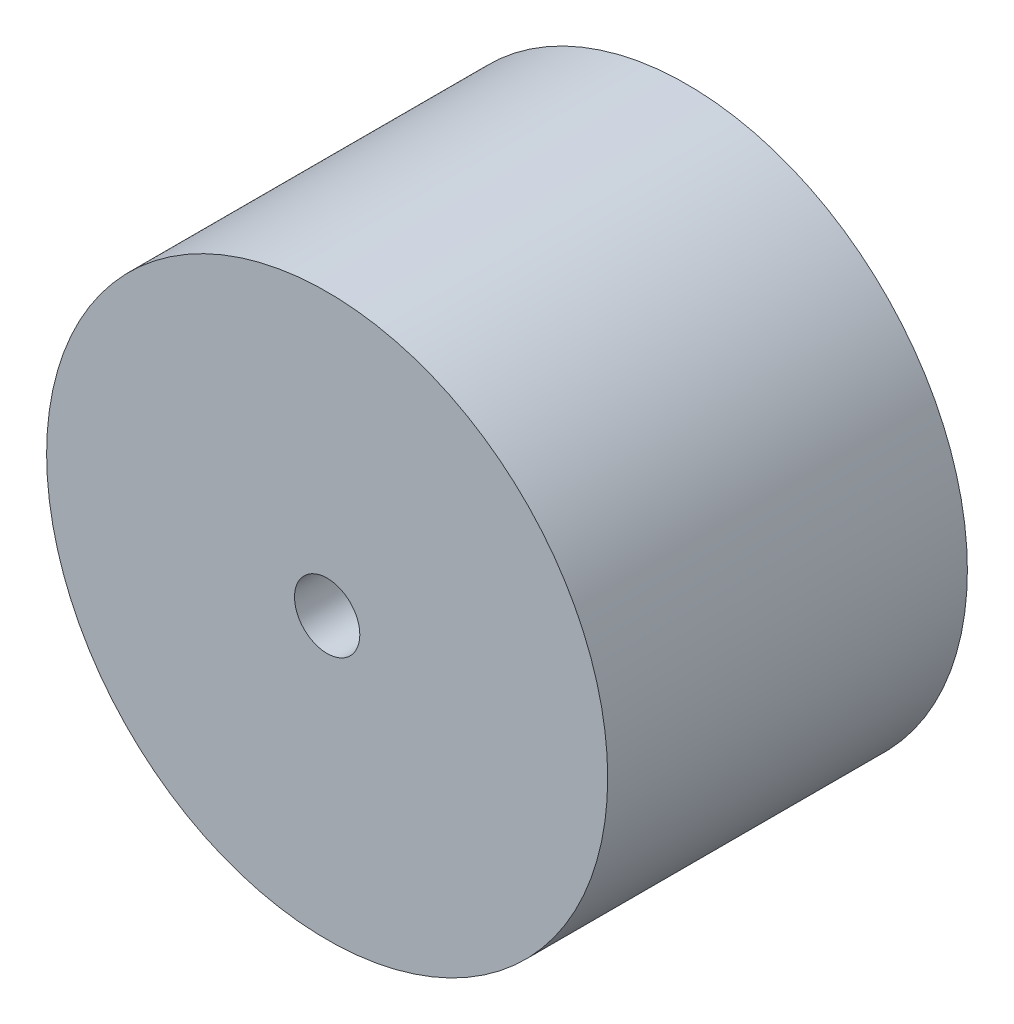
from build123d import *

# Parameters (mm, degrees)
SKETCH1_R           = 3.9
BOSS_EXTRUDE1_DEPTH = 5
SKETCH2_R           = 0.454
CUT_EXTRUDE1_DEPTH  = 5


with BuildPart() as part:
    # Sketch1 → Boss-Extrude1 (new body)
    with BuildSketch(Plane.XY):
        Circle(SKETCH1_R)
    extrude(amount=BOSS_EXTRUDE1_DEPTH)

    # Sketch2 → Cut-Extrude1 (cut)
    with BuildSketch(Plane.XY.offset(5)):
        Circle(SKETCH2_R)
    extrude(amount=-CUT_EXTRUDE1_DEPTH, mode=Mode.SUBTRACT)


solid = part.part
